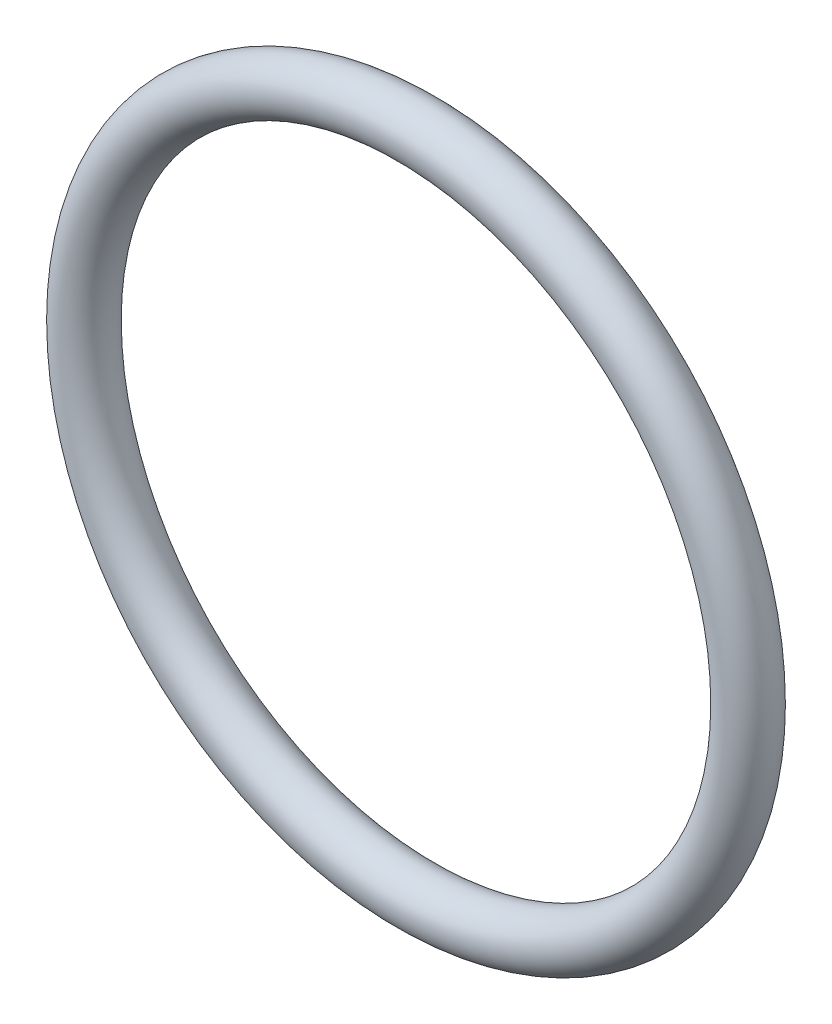
from build123d import *

# Parameters (mm, degrees)
SKETCH2_R = 1.7653


with BuildPart() as part:
    # Sketch2 → Revolve1 (revolve)
    with BuildSketch(Plane(origin=(0, 0, 0), x_dir=(1, 0, 0), z_dir=(0, 1, 0))):
        with Locations((-22.1996, 0)):
            Circle(SKETCH2_R)
    revolve(axis=Axis((0, 0, 1.7653), (0, 0, -1)))


solid = part.part
